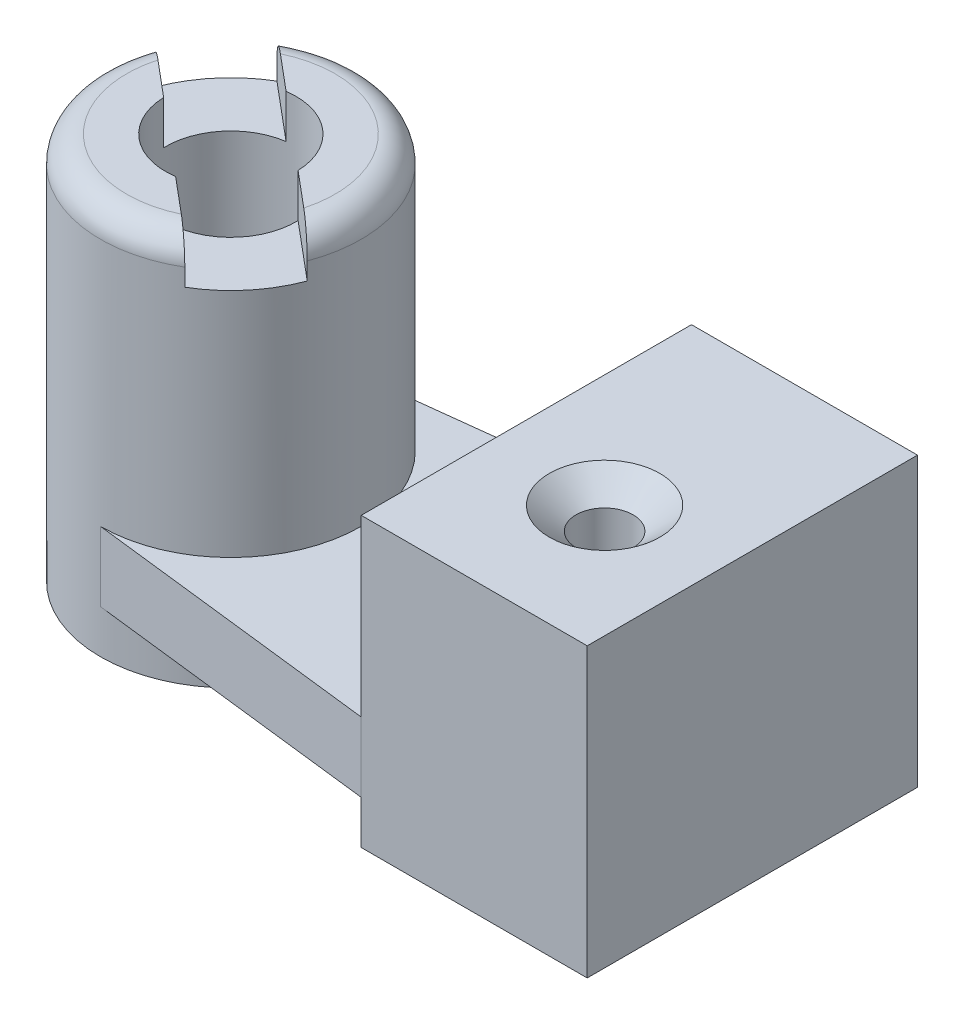
from build123d import *

# Parameters (mm, degrees)
SKETCH1_W                                           = 66.04
SKETCH1_H                                           = 96.52
BOSS_EXTRUDE1_DEPTH                                 = 84.074
BOSS_EXTRUDE2_START                                 = 12.7
BOSS_EXTRUDE2_DEPTH                                 = 20.32
SKETCH1_4_R                                         = 19.05
BOSS_EXTRUDE3_DEPTH                                 = 113.284
FILLET1_R                                           = 7.62
CSK_FOR_5_8_FLAT_HEAD_MACHINE_SCREW_100_D           = 16.66748
CSK_FOR_5_8_FLAT_HEAD_MACHINE_SCREW_100_DEPTH       = 50.8
CSK_FOR_5_8_FLAT_HEAD_MACHINE_SCREW_100_CSINK_D     = 32.3088
CSK_FOR_5_8_FLAT_HEAD_MACHINE_SCREW_100_CSINK_ANGLE = 100
CSK_FOR_5_8_FLAT_HEAD_MACHINE_SCREW_100_TIP         = 5.007416175
CUT_EXTRUDE1_START                                  = -12.7
CUT_EXTRUDE1_DEPTH                                  = 12.7


with BuildPart() as part:
    # Sketch1 → Boss-Extrude1 (new body)
    with BuildSketch(Plane(origin=(0, 0, 0), x_dir=(1, 0, 0), z_dir=(0, 1, 0))):
        with Locations((-33.02, 48.26)):
            Rectangle(SKETCH1_W, SKETCH1_H)
    extrude(amount=BOSS_EXTRUDE1_DEPTH)

    # Sketch1_3 → Boss-Extrude2 (add)
    with BuildSketch(Plane(origin=(0, 0, 0), x_dir=(1, 0, 0), z_dir=(0, 1, 0)).offset(BOSS_EXTRUDE2_START)):
        with BuildLine():
            Line((-152.4, 10.16), (-66.04, 0))
            Line((-66.04, 0), (-66.04, 96.52))
            Line((-66.04, 96.52), (-152.4, 86.36))
            ThreePointArc((-152.4, 86.36), (-125.459231637, 75.200768363), (-114.3, 48.26))
            ThreePointArc((-114.3, 48.26), (-125.459231637, 21.319231637), (-152.4, 10.16))
        make_face()
    extrude(amount=BOSS_EXTRUDE2_DEPTH)

    # Sketch1_4 → Boss-Extrude3 (add)
    with BuildSketch(Plane(origin=(0, 0, 0), x_dir=(1, 0, 0), z_dir=(0, 1, 0))):
        with BuildLine():
            ThreePointArc((-152.4, 86.36), (-190.5, 48.26), (-152.4, 10.16))
            ThreePointArc((-152.4, 10.16), (-125.459231637, 21.319231637), (-114.3, 48.26))
            ThreePointArc((-114.3, 48.26), (-125.459231637, 75.200768363), (-152.4, 86.36))
        make_face()
        with Locations((-152.4, 48.26)):
            Circle(SKETCH1_4_R, mode=Mode.SUBTRACT)
    extrude(amount=BOSS_EXTRUDE3_DEPTH)

    # Fillet1
    fillet1_edges = [part.edges().sort_by_distance(p)[0] for p in [
        (-190.5, 113.284, -48.26),
    ]]
    fillet(fillet1_edges, radius=FILLET1_R)

    # CSK for 5_8 Flat Head Machine Screw _100
    with Locations(Plane(origin=(0, 84.074, 0), x_dir=(1, 0, 0), z_dir=(0, 1, 0))):
        with Locations((-33.02, 38.1)):
            CounterSinkHole(CSK_FOR_5_8_FLAT_HEAD_MACHINE_SCREW_100_D / 2, CSK_FOR_5_8_FLAT_HEAD_MACHINE_SCREW_100_CSINK_D / 2, depth=CSK_FOR_5_8_FLAT_HEAD_MACHINE_SCREW_100_DEPTH, counter_sink_angle=CSK_FOR_5_8_FLAT_HEAD_MACHINE_SCREW_100_CSINK_ANGLE)
            with Locations((0, 0, -(CSK_FOR_5_8_FLAT_HEAD_MACHINE_SCREW_100_DEPTH + CSK_FOR_5_8_FLAT_HEAD_MACHINE_SCREW_100_TIP / 2))):  # 118° drill point
                Cone(0, CSK_FOR_5_8_FLAT_HEAD_MACHINE_SCREW_100_D / 2, CSK_FOR_5_8_FLAT_HEAD_MACHINE_SCREW_100_TIP, mode=Mode.SUBTRACT)

    # Sketch4 → Cut-Extrude1 (cut)
    with BuildSketch(Plane(origin=(0, 113.284, 0), x_dir=(1, 0, 0), z_dir=(0, 1, 0)).offset(CUT_EXTRUDE1_START)):
        with BuildLine():
            Line((-181.640283335, 89.374183536), (-197.967088621, 69.916654681))
            Line((-197.967088621, 69.916654681), (-171.440491942, 47.658197191))
            ThreePointArc((-171.440491942, 47.658197191), (-166.993146641, 60.505103965), (-155.113686656, 67.115726046))
            Line((-155.113686656, 67.115726046), (-181.640283335, 89.374183536))
        make_face()
        with BuildLine():
            Line((-87.056717789, 10.009148571), (-133.359508058, 48.861802809))
            ThreePointArc((-133.359508058, 48.861802809), (-137.806853359, 36.014896035), (-149.686313344, 29.404273954))
            Line((-149.686313344, 29.404273954), (-103.383523075, -9.448380284))
            Line((-103.383523075, -9.448380284), (-87.056717789, 10.009148571))
        make_face()
    extrude(amount=CUT_EXTRUDE1_DEPTH, mode=Mode.SUBTRACT)


solid = part.part
